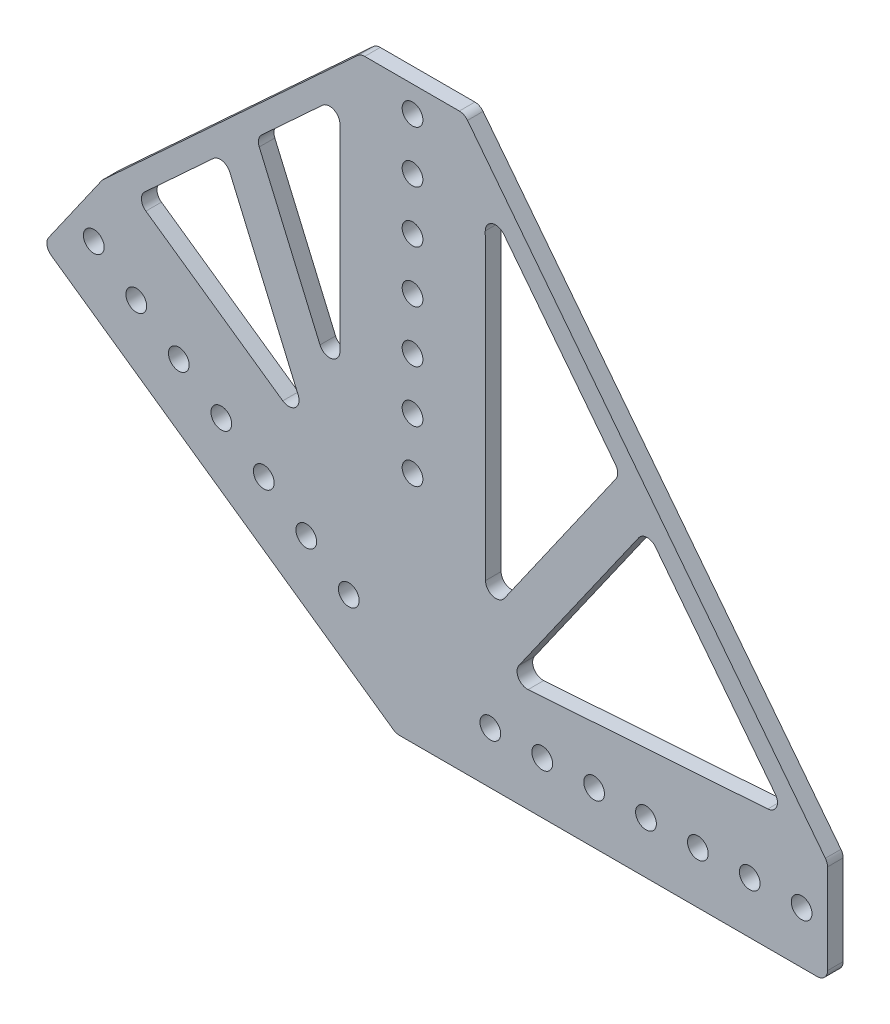
from build123d import *

# Parameters (mm, degrees)
BOSS_EXTRUDE3_DEPTH = 3.81
SKETCH1_7_R         = 2.54
CUT_EXTRUDE6_DEPTH  = 3.81
CUT_EXTRUDE7_DEPTH  = 174.732454112
FILLET1_R           = 2.54
FILLET2_R           = 2.54


with BuildPart() as part:
    # Sketch1 → Boss-Extrude3 (new body)
    with BuildSketch(Plane.XY):
        Polygon((-103.210268441, 60.572134971), (-88.641426958, 81.378596896), (-25.4, 139.7), (0, 139.7), (88.9, 25.4), (88.9, 0), (-16.704294619, 0), align=None)
    extrude(amount=BOSS_EXTRUDE3_DEPTH)

    # Sketch1_7 → Cut-Extrude6 (cut)
    with BuildSketch(Plane.XY):
        with Locations((-12.7, 57.15)):
            Circle(SKETCH1_7_R)
        with Locations((-12.7, 69.85)):
            Circle(SKETCH1_7_R)
        with Locations((-12.7, 82.55)):
            Circle(SKETCH1_7_R)
        with Locations((-12.7, 95.25)):
            Circle(SKETCH1_7_R)
        with Locations((-12.7, 107.95)):
            Circle(SKETCH1_7_R)
        with Locations((-12.7, 120.65)):
            Circle(SKETCH1_7_R)
        with Locations((-12.7, 133.35)):
            Circle(SKETCH1_7_R)
        with Locations((6.35, 12.7)):
            Circle(SKETCH1_7_R)
        with Locations((19.05, 12.7)):
            Circle(SKETCH1_7_R)
        with Locations((31.75, 12.7)):
            Circle(SKETCH1_7_R)
        with Locations((44.45, 12.7)):
            Circle(SKETCH1_7_R)
        with Locations((57.15, 12.7)):
            Circle(SKETCH1_7_R)
        with Locations((69.85, 12.7)):
            Circle(SKETCH1_7_R)
        with Locations((82.55, 12.7)):
            Circle(SKETCH1_7_R)
        with Locations((-28.304846444, 23.626631112)):
            Circle(SKETCH1_7_R)
        with Locations((-38.708077406, 30.911051854)):
            Circle(SKETCH1_7_R)
        with Locations((-49.111308369, 38.195472596)):
            Circle(SKETCH1_7_R)
        with Locations((-59.514539331, 45.479893337)):
            Circle(SKETCH1_7_R)
        with Locations((-69.917770294, 52.764314079)):
            Circle(SKETCH1_7_R)
        with Locations((-80.321001256, 60.048734821)):
            Circle(SKETCH1_7_R)
        with Locations((-90.724232219, 67.333155562)):
            Circle(SKETCH1_7_R)
    extrude(amount=CUT_EXTRUDE6_DEPTH, mode=Mode.SUBTRACT)

    # Sketch2 → Cut-Extrude7 (cut, through all)
    with BuildSketch(Plane.XY.offset(3.81)):
        Polygon((-80.559662327, 81.92121929), (-37.140287646, 51.518645834), (-58.849974987, 101.941947594), align=None)
        Polygon((-30.48, 128.104809927), (-50.932108739, 109.243823775), (-30.48, 61.7413962), align=None)
        Polygon((5.178673612, 35.321443219), (38.137547923, 82.391593871), (5.094015595, 124.876135436), align=None)
        Polygon((79.029766265, 29.815884574), (44.656622028, 74.009927164), (10.283477792, 25.107422311), align=None)
    extrude(amount=-CUT_EXTRUDE7_DEPTH, mode=Mode.SUBTRACT)

    # Fillet1
    fillet1_edges = [part.edges().sort_by_distance(p)[0] for p in [
        (10.283477792, 25.107422311, 1.905),
        (44.656622028, 74.009927164, 1.905),
        (79.029766265, 29.815884574, 1.905),
        (5.178673612, 35.321443219, 1.905),
        (38.137547923, 82.391593871, 1.905),
        (5.094015595, 124.876135436, 1.905),
        (-50.932108739, 109.243823775, 1.905),
        (-30.48, 128.104809927, 1.905),
        (-30.48, 61.7413962, 1.905),
        (-37.140287646, 51.518645834, 1.905),
        (-80.559662327, 81.92121929, 1.905),
        (-58.849974987, 101.941947594, 1.905),
    ]]
    fillet(fillet1_edges, radius=FILLET1_R)

    # Fillet2
    fillet2_edges = [part.edges().sort_by_distance(p)[0] for p in [
        (-103.210268441, 60.572134971, 1.905),
        (-88.641426958, 81.378596896, 1.905),
        (-25.4, 139.7, 1.905),
        (0, 139.7, 1.905),
        (88.9, 25.4, 1.905),
        (88.9, 0, 1.905),
        (-16.704294619, 0, 1.905),
    ]]
    fillet(fillet2_edges, radius=FILLET2_R)


solid = part.part
